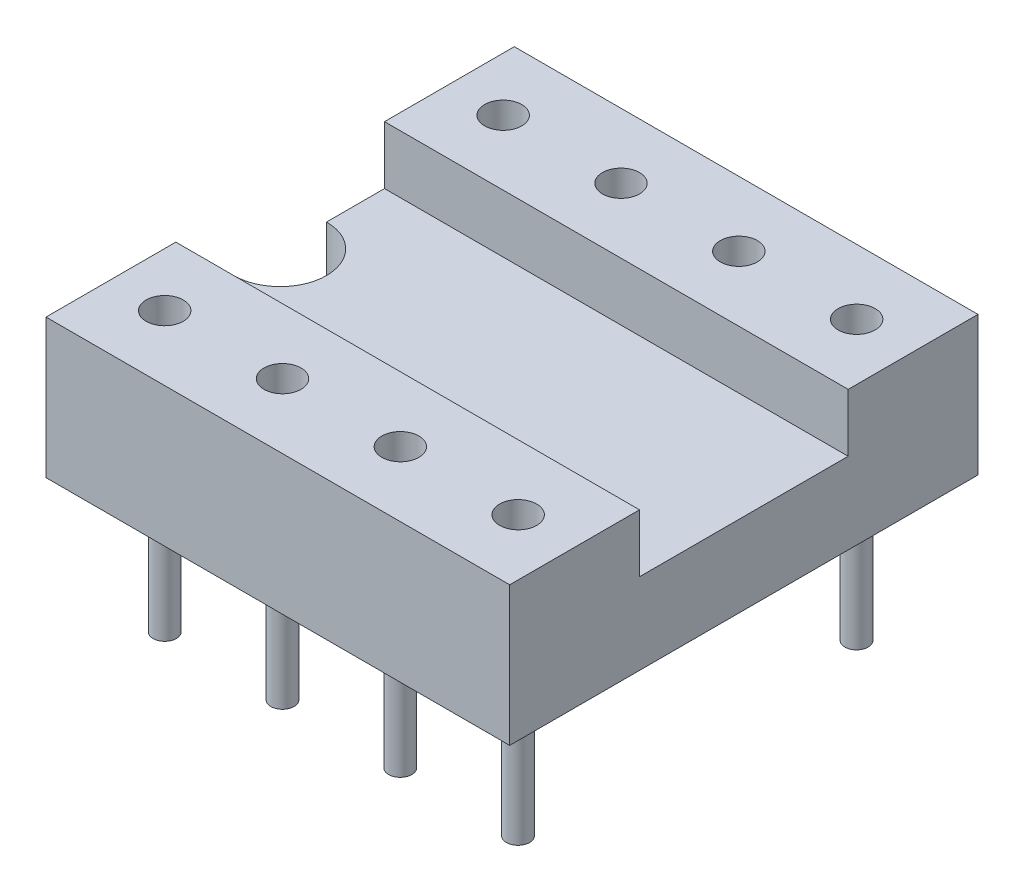
from build123d import *

# Parameters (mm, degrees)
EXTRUSION1_DEPTH        = 10
ENL_V_MAT_EXTRU_1_DEPTH = 2.75
ESQUISSE3_R             = 0.4
ENL_V_MAT_EXTRU_2_DEPTH = 2.5
ESQUISSE5_R             = 0.25
EXTRUSION2_DEPTH        = 3


with BuildPart() as part:
    # Esquisse1 → Extrusion1 (new body)
    with BuildSketch(Plane(origin=(0, 0, 0), x_dir=(0, 0, -1), z_dir=(1, 0, 0))):
        Polygon((-2.25, 1.75), (-2.25, 3), (-5.05, 3), (-5.05, 0), (5.05, 0), (5.05, 3), (2.25, 3), (2.25, 1.75), align=None)
    extrude(amount=EXTRUSION1_DEPTH)

    # Esquisse2 → Enlèv. mat.-Extru.1 (cut, through all)
    with BuildSketch(Plane(origin=(0, 1.75, 0), x_dir=(-1, 0, 0), z_dir=(0, 1, 0))):
        with BuildLine():
            Line((0, -1), (0, 1))
            ThreePointArc((0, 1), (-1, 0), (0, -1))
        make_face()
    extrude(amount=-ENL_V_MAT_EXTRU_1_DEPTH, mode=Mode.SUBTRACT)

    # Esquisse3 → Enlèv. mat.-Extru.2 (cut)
    with BuildSketch(Plane(origin=(0, 3, 0), x_dir=(-1, 0, 0), z_dir=(0, 1, 0))):
        with Locations(Location((-1.16, 3.65, 0), (0, 0, 90))):  # turned: the seam where the file's is
            Circle(ESQUISSE3_R)
        with Locations(Location((-1.16, -3.65, 0), (0, 0, 270))):  # turned: the seam where the file's is
            Circle(ESQUISSE3_R)
        with Locations(Location((-3.701, 3.65, 0), (0, 0, 90))):  # turned: the seam where the file's is
            Circle(ESQUISSE3_R)
        with Locations(Location((-3.701, -3.65, 0), (0, 0, 270))):  # turned: the seam where the file's is
            Circle(ESQUISSE3_R)
        with Locations(Location((-6.242, 3.65, 0), (0, 0, 90))):  # turned: the seam where the file's is
            Circle(ESQUISSE3_R)
        with Locations(Location((-6.242, -3.65, 0), (0, 0, 270))):  # turned: the seam where the file's is
            Circle(ESQUISSE3_R)
        with Locations(Location((-8.783, 3.65, 0), (0, 0, 90))):  # turned: the seam where the file's is
            Circle(ESQUISSE3_R)
        with Locations(Location((-8.783, -3.65, 0), (0, 0, 270))):  # turned: the seam where the file's is
            Circle(ESQUISSE3_R)
    extrude(amount=-ENL_V_MAT_EXTRU_2_DEPTH, mode=Mode.SUBTRACT)

    # Esquisse5 → Extrusion2 (add)
    with BuildSketch(Plane.XZ):
        with Locations(Location((1.16, 3.65, 0), (0, 0, 90))):  # turned: the seam where the file's is
            Circle(ESQUISSE5_R)
        with Locations(Location((1.16, -3.65, 0), (0, 0, 90))):  # turned: the seam where the file's is
            Circle(ESQUISSE5_R)
        with Locations(Location((3.7, -3.65, 0), (0, 0, 90))):  # turned: the seam where the file's is
            Circle(ESQUISSE5_R)
        with Locations(Location((3.7, 3.65, 0), (0, 0, 90))):  # turned: the seam where the file's is
            Circle(ESQUISSE5_R)
        with Locations(Location((6.24, -3.65, 0), (0, 0, 90))):  # turned: the seam where the file's is
            Circle(ESQUISSE5_R)
        with Locations(Location((6.24, 3.65, 0), (0, 0, 90))):  # turned: the seam where the file's is
            Circle(ESQUISSE5_R)
        with Locations(Location((8.78, -3.65, 0), (0, 0, 90))):  # turned: the seam where the file's is
            Circle(ESQUISSE5_R)
        with Locations(Location((8.78, 3.65, 0), (0, 0, 90))):  # turned: the seam where the file's is
            Circle(ESQUISSE5_R)
    extrude(amount=EXTRUSION2_DEPTH)


solid = part.part
